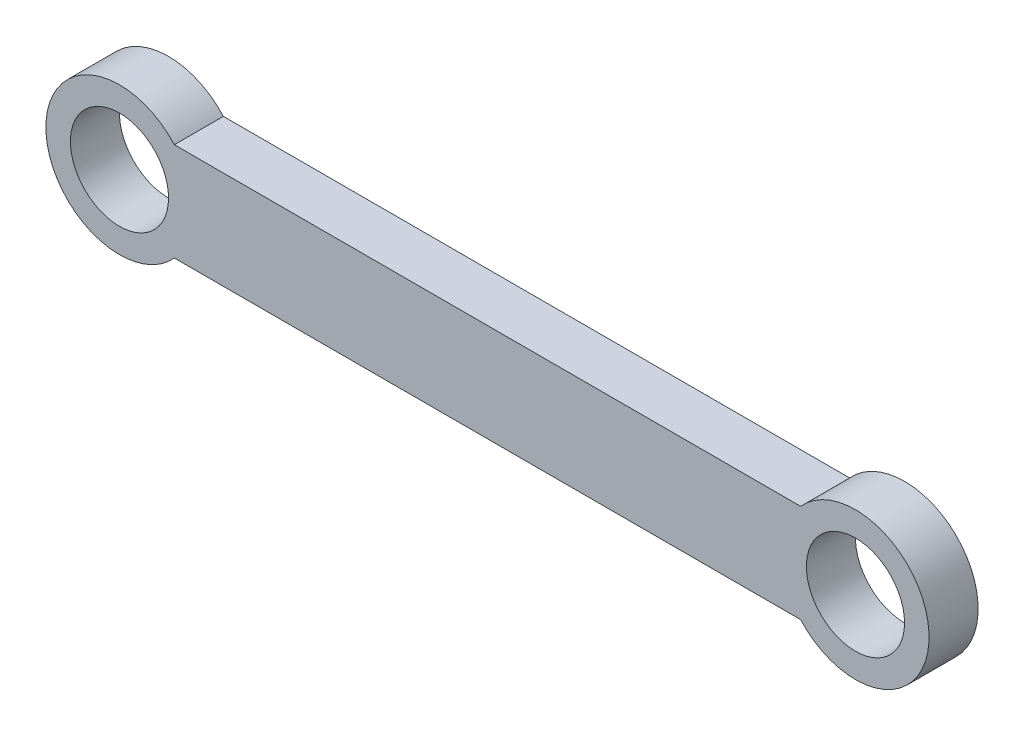
from build123d import *

# Parameters (mm, degrees)
SKETCH_1_R      = 2
EXTRUDE_1_DEPTH = 2


with BuildPart() as part:
    # 草图1 → 凸台-拉伸1 (new body)
    with BuildSketch(Plane.XY):
        with BuildLine():
            Line((-12.763932023, 2), (12.763932023, 2))
            ThreePointArc((12.763932023, 2), (18, 0), (12.763932023, -2))
            Line((12.763932023, -2), (-12.763932023, -2))
            ThreePointArc((-12.763932023, -2), (-18, 0), (-12.763932023, 2))
        make_face()
        with Locations((-15, 0)):
            Circle(SKETCH_1_R, mode=Mode.SUBTRACT)
        with Locations((15, 0)):
            Circle(SKETCH_1_R, mode=Mode.SUBTRACT)
    extrude(amount=EXTRUDE_1_DEPTH)


solid = part.part
